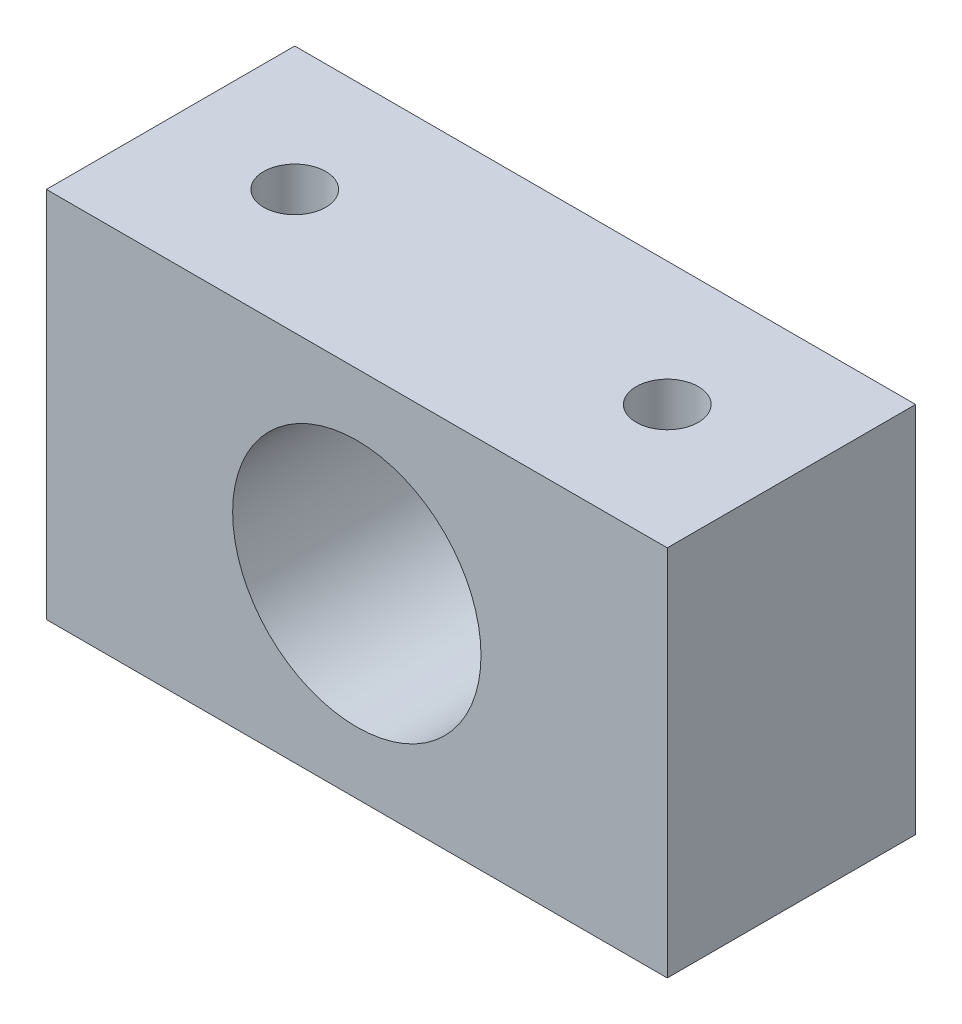
from build123d import *

# Parameters (mm, degrees)
SKETCH1_W           = 31.75
SKETCH1_H           = 19.05
BOSS_EXTRUDE1_DEPTH = 12.7
SKETCH2_R           = 6.35
CUT_EXTRUDE1_DEPTH  = 12.7
SKETCH3_R           = 1.5875
CUT_EXTRUDE2_DEPTH  = 12.7


with BuildPart() as part:
    # Sketch1 → Boss-Extrude1 (new body)
    with BuildSketch(Plane.XY):
        Rectangle(SKETCH1_W, SKETCH1_H)
    extrude(amount=BOSS_EXTRUDE1_DEPTH)

    # Sketch2 → Cut-Extrude1 (cut)
    with BuildSketch(Plane.XY.offset(12.7)):
        Circle(SKETCH2_R)
    extrude(amount=-CUT_EXTRUDE1_DEPTH, mode=Mode.SUBTRACT)

    # Sketch3 → Cut-Extrude2 (cut)
    with BuildSketch(Plane(origin=(0, 9.525, 0), x_dir=(1, 0, 0), z_dir=(0, 1, 0))):
        with Locations((-9.525, -6.35)):
            Circle(SKETCH3_R)
        with Locations((9.525, -6.35)):
            Circle(SKETCH3_R)
    extrude(amount=-CUT_EXTRUDE2_DEPTH, mode=Mode.SUBTRACT)


solid = part.part
